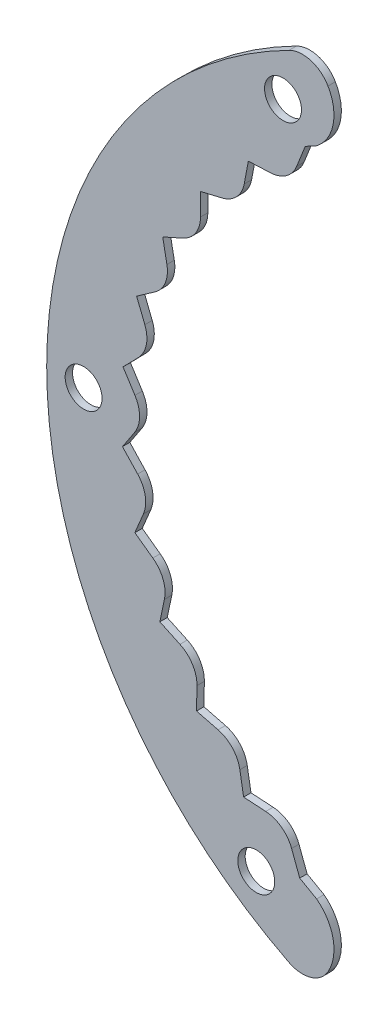
from build123d import *

# Parameters (mm, degrees)
IZIM1_R                     = 2.5
Y_KSEKLIK_EKSTR_ZYON1_DEPTH = 1


with BuildPart() as part:
    # Çizim1 → Yükseklik-Ekstrüzyon1 (new body)
    with BuildSketch(Plane.XY):
        with BuildLine():
            Line((-23.446136356, -44.161959762), (-25.73775467, -42.866863479))
            Line((-25.73775467, -42.866863479), (-26.834295942, -39.938466016))
            ThreePointArc((-26.834295942, -39.938466016), (-28.201527977, -38.125336415), (-30.335428898, -37.348658075))
            Line((-30.335428898, -37.348658075), (-33.334907776, -37.164700371))
            Line((-33.334907776, -37.164700371), (-33.842709051, -34.202800331))
            ThreePointArc((-33.842709051, -34.202800331), (-34.84597704, -32.165592505), (-36.7965457, -31.002818113))
            Line((-36.7965457, -31.002818113), (-39.708425324, -30.260072511))
            Line((-39.708425324, -30.260072511), (-39.652227319, -27.255483394))
            ThreePointArc((-39.652227319, -27.255483394), (-40.255989993, -25.066366444), (-41.954126526, -23.558687864))
            Line((-41.954126526, -23.558687864), (-44.675252109, -22.283466496))
            Line((-44.675252109, -22.283466496), (-44.057045667, -19.342627369))
            ThreePointArc((-44.057045667, -19.342627369), (-44.239914432, -17.079151855), (-45.625461503, -15.279979352))
            Line((-45.625461503, -15.279979352), (-48.059435816, -13.517457571))
            Line((-48.059435816, -13.517457571), (-46.901121207, -10.744549126))
            ThreePointArc((-46.901121207, -10.744549126), (-46.656617846, -8.486899797), (-47.680491761, -6.459969953))
            Line((-47.680491761, -6.459969953), (-49.741090048, -4.272585973))
            Line((-49.741090048, -4.272585973), (-48.083701146, -1.765839874))
            ThreePointArc((-48.083701146, -1.765839874), (-47.420487313, 0.406004917), (-48.046416828, 2.588887101))
            Line((-48.046416828, 2.588887101), (-49.660641368, 5.123644113))
            Line((-49.660641368, 5.123644113), (-47.562892001, 7.275425136))
            ThreePointArc((-47.562892001, 7.275425136), (-46.504462376, 9.284526705), (-46.710273625, 11.546031539))
            Line((-46.710273625, 11.546031539), (-47.82093971, 14.338366552))
            Line((-47.82093971, 14.338366552), (-45.357143694, 16.058954583))
            ThreePointArc((-45.357143694, 16.058954583), (-43.940993675, 17.834139505), (-43.719395692, 20.094152054))
            Line((-43.719395692, 20.094152054), (-44.287157421, 23.045145208))
            Line((-44.287157421, 23.045145208), (-41.54459596, 24.273587558))
            ThreePointArc((-41.54459596, 24.273587558), (-39.820893366, 25.751969023), (-39.17973637, 27.930427214))
            Line((-39.17973637, 27.930427214), (-39.184480502, 30.935538106))
            Line((-39.184480502, 30.935538106), (-36.260310201, 31.628316593))
            ThreePointArc((-36.260310201, 31.628316593), (-34.290118058, 32.757522199), (-33.252115355, 34.777253066))
            Line((-33.252115355, 34.777253066), (-32.693673826, 37.730024144))
            Line((-32.693673826, 37.730024144), (-29.691484877, 37.862596744))
            ThreePointArc((-29.691484877, 37.862596744), (-27.544598222, 38.602623821), (-26.146521576, 40.39207739))
            Line((-26.146521576, 40.39207739), (-25, 43.301270189))
            ThreePointArc((-25, 43.301270189), (-24.226890609, 43.73851588), (-23.446136356, 44.161959762))
            ThreePointArc((-23.446136356, 44.161959762), (-21.212806241, 47.755648425), (-21.906244367, 51.929556087))
            ThreePointArc((-21.906244367, 51.929556087), (-24.232021318, 53.76021953), (-27.179564099, 53.490852446))
            ThreePointArc((-27.179564099, 53.490852446), (-59.999999835, 0.004450967), (-27.1875, -53.486819346))
            Line((-27.1875, -53.486819346), (-27.179564099, -53.490852446))
            ThreePointArc((-27.179564099, -53.490852446), (-24.232021318, -53.76021953), (-21.906244367, -51.929556087))
            ThreePointArc((-21.906244367, -51.929556087), (-21.212806241, -47.755648425), (-23.446136356, -44.161959762))
        make_face()
        with Locations((-31.620079453, -45.001895242)):
            Circle(IZIM1_R, mode=Mode.SUBTRACT)
        with Locations((-55, 0)):
            Circle(IZIM1_R, mode=Mode.SUBTRACT)
        with Locations((-28.000624989, 47.338831842)):
            Circle(IZIM1_R, mode=Mode.SUBTRACT)
    extrude(amount=Y_KSEKLIK_EKSTR_ZYON1_DEPTH)


solid = part.part
